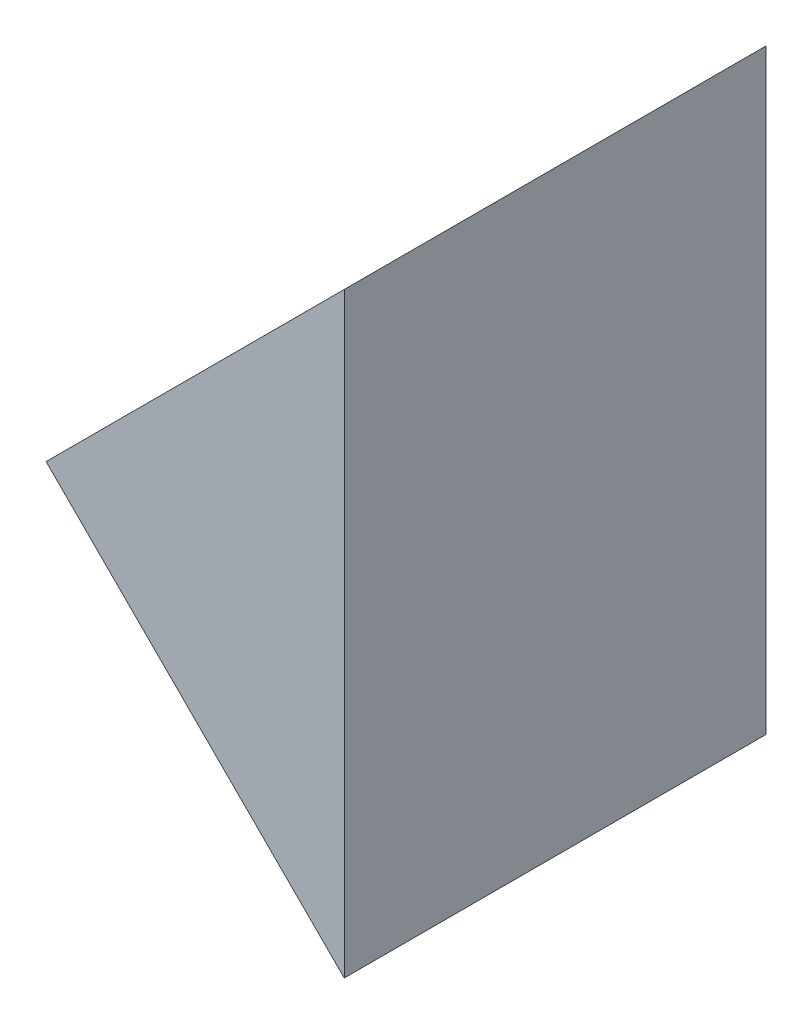
from build123d import *

# Parameters (mm, degrees)
EXTRUDE_1_DEPTH = 20


with BuildPart() as part:
    # 草图1 → 凸台-拉伸1 (new body)
    with BuildSketch(Plane.XY):
        Polygon((196.707346195, 60.06111063), (182.565210571, 45.918975006), (196.707346195, 31.776839383), align=None)
    extrude(amount=EXTRUDE_1_DEPTH)


solid = part.part
